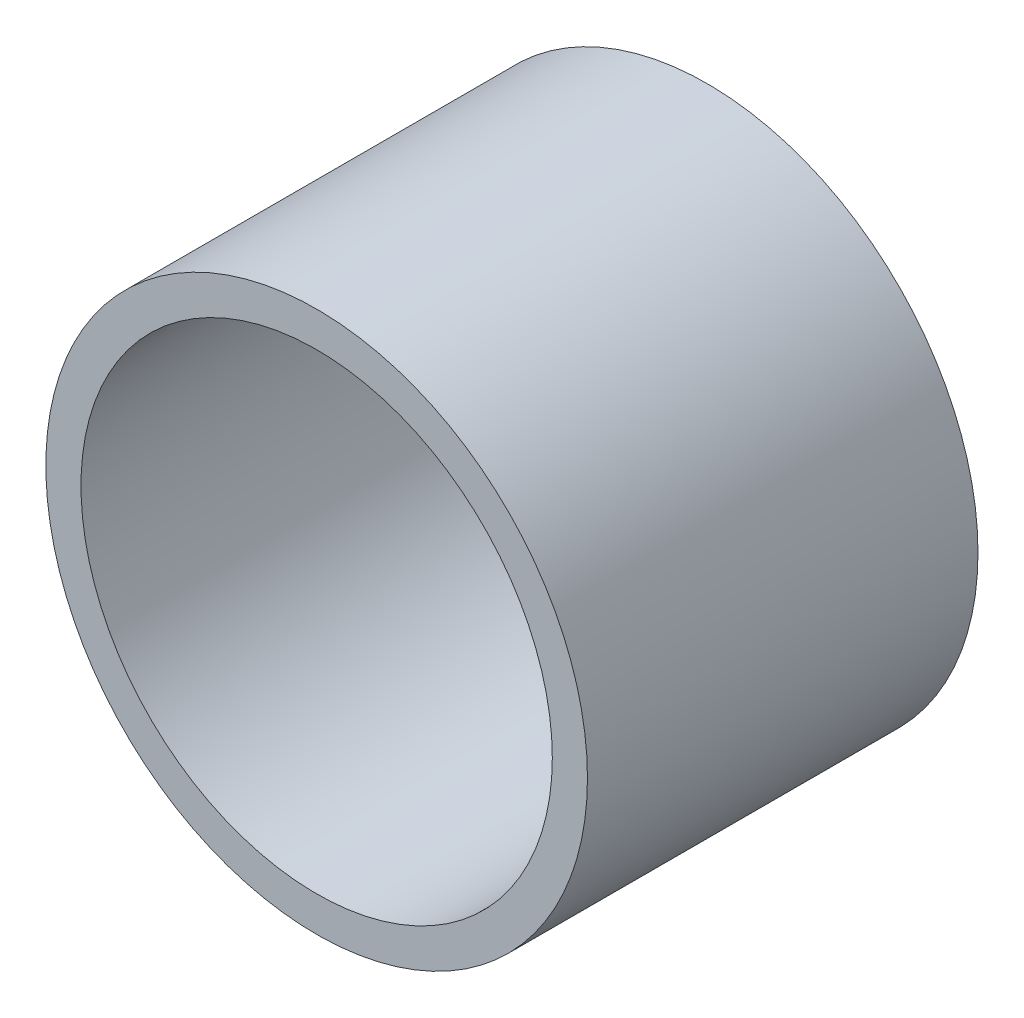
from build123d import *

# Parameters (mm, degrees)
CROQUIS1_R              = 30.165
CROQUIS1_R_2            = 26.25
SALIENTE_EXTRUIR1_DEPTH = 43.5


with BuildPart() as part:
    # Croquis1 → Saliente-Extruir1 (new body)
    with BuildSketch(Plane.XY):
        Circle(CROQUIS1_R)
        Circle(CROQUIS1_R_2, mode=Mode.SUBTRACT)
    extrude(amount=SALIENTE_EXTRUIR1_DEPTH)


solid = part.part
